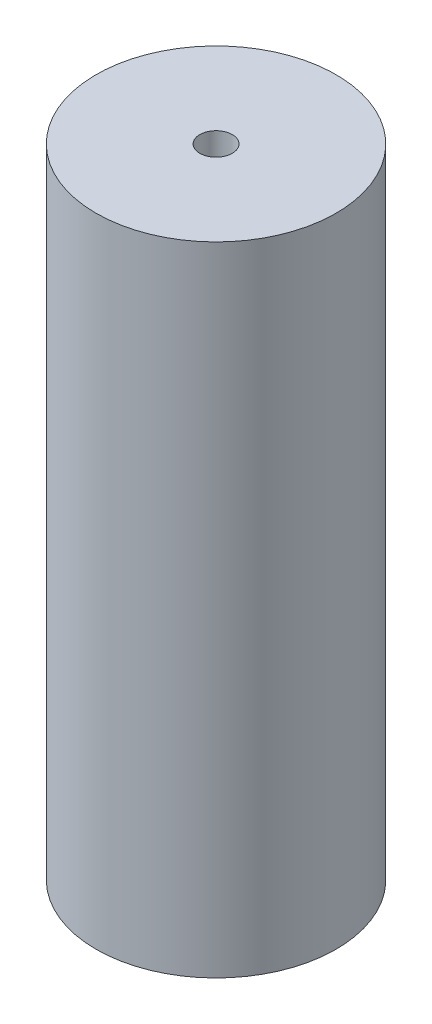
from build123d import *

# Parameters (mm, degrees)
SKETCH1_R           = 23.9141
BOSS_EXTRUDE1_DEPTH = 127
CUT_EXTRUDE1_REACH  = 129
SKETCH2_R           = 3.2385


with BuildPart() as part:
    # Sketch1 → Boss-Extrude1 (new body)
    with BuildSketch(Plane(origin=(0, 0, 0), x_dir=(1, 0, 0), z_dir=(0, 1, 0))):
        Circle(SKETCH1_R)
    extrude(amount=BOSS_EXTRUDE1_DEPTH)

    # Sketch2 → Cut-Extrude1 (cut, up to next)
    with BuildSketch(Plane(origin=(0, 127, 0), x_dir=(1, 0, 0), z_dir=(0, 1, 0)), mode=Mode.PRIVATE) as cut_extrude1_sk1:
        Circle(SKETCH2_R)
    cut_extrude1_tool1 = extrude(cut_extrude1_sk1.sketch, amount=-CUT_EXTRUDE1_REACH, mode=Mode.PRIVATE) & part.part
    add(cut_extrude1_tool1.solids().sort_by_distance((0, 127, 0))[0], mode=Mode.SUBTRACT)


solid = part.part
